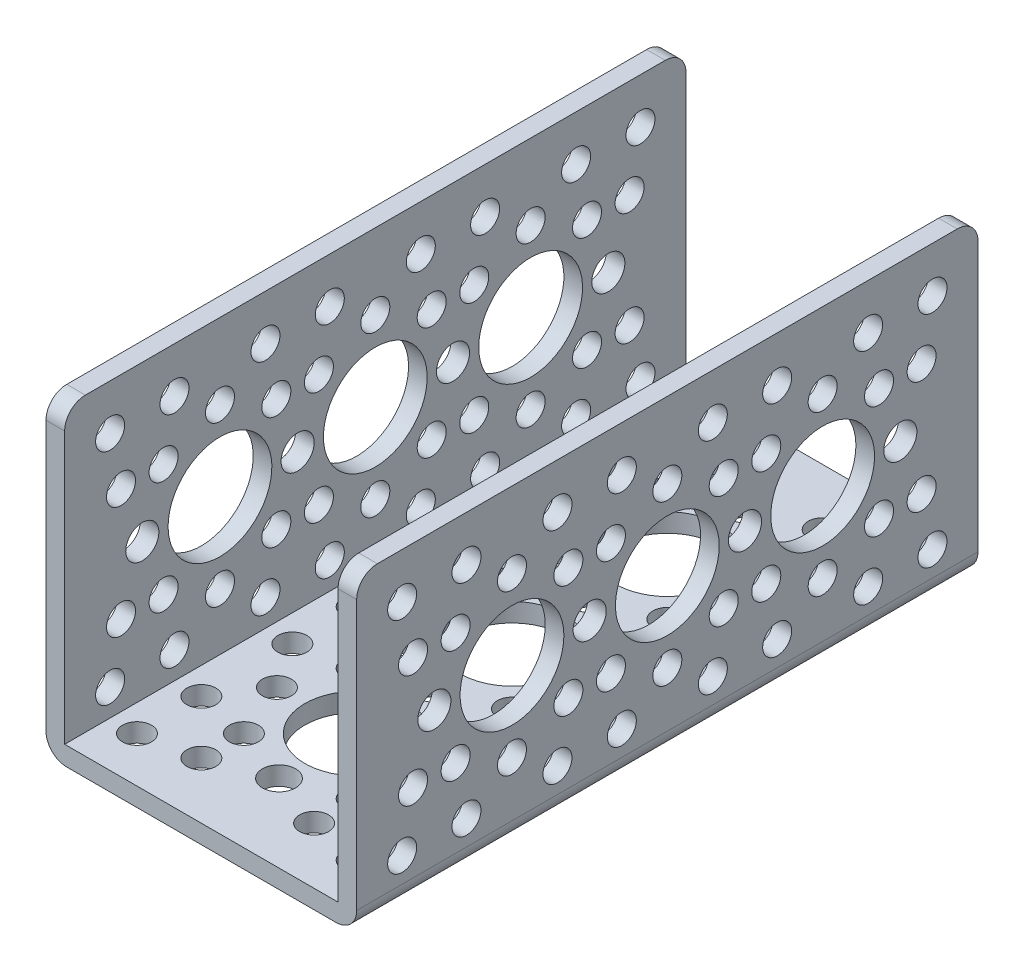
from build123d import *

# Parameters (mm, degrees)
SKETCH1_W                  = 38.1
SKETCH1_H                  = 76.2
BOSS_EXTRUDE1_DEPTH        = 38.1
SKETCH2_W                  = 33.528
SKETCH2_H                  = 35.814
CUT_EXTRUDE1_DEPTH         = 77.2
HOLE1_D                    = 12.7254
HOLE1_DEPTH                = 2.286
M3_CLEARANCE_HOLE1_D       = 3.556
M3_CLEARANCE_HOLE1_DEPTH   = 2.286
M3_5_CLEARANCE_HOLE1_D     = 4.064
M3_5_CLEARANCE_HOLE1_DEPTH = 2.286
HOLE2_D                    = 12.7254
HOLE2_DEPTH                = 38.1
M3_5_CLEARANCE_HOLE2_D     = 4.064
M3_5_CLEARANCE_HOLE2_DEPTH = 38.1
M3_CLEARANCE_HOLE2_D       = 3.556
M3_CLEARANCE_HOLE2_DEPTH   = 38.1
HOLE3_D                    = 12.7254
HOLE3_DEPTH                = 38.1
M3_CLEARANCE_HOLE3_D       = 3.556
M3_CLEARANCE_HOLE3_DEPTH   = 38.1
M3_5_CLEARANCE_HOLE3_D     = 4.064
M3_5_CLEARANCE_HOLE3_DEPTH = 38.1
FILLET1_R                  = 2.54


with BuildPart() as part:
    # Sketch1 → Boss-Extrude1 (new body)
    with BuildSketch(Plane.XZ):
        with Locations((19.05, 38.1)):
            Rectangle(SKETCH1_W, SKETCH1_H)
    extrude(amount=-BOSS_EXTRUDE1_DEPTH)

    # Sketch2 → Cut-Extrude1 (cut, through all)
    with BuildSketch(Plane.XY.offset(76.2)):
        with Locations((19.05, 20.193)):
            Rectangle(SKETCH2_W, SKETCH2_H)
    extrude(amount=-CUT_EXTRUDE1_DEPTH, mode=Mode.SUBTRACT)

    # Hole1
    with Locations(Plane(origin=(38.1, 0, 0), x_dir=(0, 0, -1), z_dir=(1, 0, 0))):
        with Locations((-38.1, 19.05), (-19.05, 19.05), (-57.15, 19.05)):
            Hole(HOLE1_D / 2, depth=HOLE1_DEPTH)

    # M3 Clearance Hole1
    with Locations(Plane(origin=(38.1, 0, 0), x_dir=(0, 0, -1), z_dir=(1, 0, 0))):
        with Locations((-62.729615818, 5.579615818), (-69.285202787, 12.135202787), (-62.729615818, 32.520384182), (-69.285202787, 25.964797213), (-13.470384182, 5.579615818), (-6.914797213, 12.135202787), (-13.470384182, 32.520384182), (-6.914797213, 25.964797213), (-43.679615818, 5.579615818), (-24.629615818, 5.579615818), (-43.679615818, 32.520384182), (-24.629615818, 32.520384182), (-70.620384182, 5.579615818), (-70.620384182, 32.520384182), (-51.570384182, 5.579615818), (-51.570384182, 32.520384182), (-50.235202787, 12.135202787), (-57.15, 9.271), (-64.064797213, 12.135202787), (-64.064797213, 25.964797213), (-57.15, 28.829), (-31.185202787, 12.135202787), (-38.1, 9.271), (-45.014797213, 12.135202787), (-45.014797213, 25.964797213), (-38.1, 28.829), (-50.235202787, 25.964797213), (-31.185202787, 25.964797213), (-32.520384182, 5.579615818), (-32.520384182, 32.520384182), (-5.579615818, 5.579615818), (-5.579615818, 32.520384182), (-12.135202787, 12.135202787), (-19.05, 9.271), (-25.964797213, 12.135202787), (-25.964797213, 25.964797213), (-19.05, 28.829), (-12.135202787, 25.964797213)):
            Hole(M3_CLEARANCE_HOLE1_D / 2, depth=M3_CLEARANCE_HOLE1_DEPTH)

    # M3.5 Clearance Hole1
    with Locations(Plane(origin=(38.1, 0, 0), x_dir=(0, 0, -1), z_dir=(1, 0, 0))):
        with Locations((-66.675, 19.05), (-47.625, 19.05), (-28.575, 19.05), (-9.525, 19.05)):
            Hole(M3_5_CLEARANCE_HOLE1_D / 2, depth=M3_5_CLEARANCE_HOLE1_DEPTH)

    # Hole2
    with Locations(Plane(origin=(0, 0, 0), x_dir=(-1, 0, 0), z_dir=(0, -1, 0))):
        with Locations((-19.05, -57.15), (-19.05, -38.1), (-19.05, -19.05)):
            Hole(HOLE2_D / 2, depth=HOLE2_DEPTH)

    # M3.5 Clearance Hole2
    with Locations(Plane(origin=(0, 0, 0), x_dir=(-1, 0, 0), z_dir=(0, -1, 0))):
        with Locations((-19.05, -66.675), (-19.05, -47.625), (-19.05, -28.575), (-19.05, -9.525)):
            Hole(M3_5_CLEARANCE_HOLE2_D / 2, depth=M3_5_CLEARANCE_HOLE2_DEPTH)

    # M3 Clearance Hole2
    with Locations(Plane(origin=(0, 0, 0), x_dir=(-1, 0, 0), z_dir=(0, -1, 0))):
        with Locations((-5.579615818, -70.620384182), (-5.579615818, -62.729615818), (-12.135202787, -69.285202787), (-32.520384182, -70.620384182), (-32.520384182, -62.729615818), (-25.964797213, -69.285202787), (-5.579615818, -51.570384182), (-5.579615818, -43.679615818), (-32.520384182, -51.570384182), (-32.520384182, -43.679615818), (-12.135202787, -50.235202787), (-9.271, -57.15), (-12.135202787, -64.064797213), (-25.964797213, -64.064797213), (-28.829, -57.15), (-25.964797213, -50.235202787), (-9.271, -38.1), (-12.135202787, -45.014797213), (-25.964797213, -45.014797213), (-28.829, -38.1), (-5.579615818, -32.520384182), (-5.579615818, -24.629615818), (-12.135202787, -31.185202787), (-32.520384182, -32.520384182), (-32.520384182, -24.629615818), (-25.964797213, -31.185202787), (-5.579615818, -5.579615818), (-5.579615818, -13.470384182), (-12.135202787, -6.914797213), (-32.520384182, -5.579615818), (-32.520384182, -13.470384182), (-25.964797213, -6.914797213), (-12.135202787, -12.135202787), (-9.271, -19.05), (-12.135202787, -25.964797213), (-25.964797213, -25.964797213), (-28.829, -19.05), (-25.964797213, -12.135202787)):
            Hole(M3_CLEARANCE_HOLE2_D / 2, depth=M3_CLEARANCE_HOLE2_DEPTH)

    # Hole3
    with Locations(Plane.ZY):
        with Locations((38.1, 19.05), (19.05, 19.05), (57.15, 19.05)):
            Hole(HOLE3_D / 2, depth=HOLE3_DEPTH)

    # M3 Clearance Hole3
    with Locations(Plane.ZY):
        with Locations((62.729615818, 5.579615818), (69.285202787, 12.135202787), (62.729615818, 32.520384182), (69.285202787, 25.964797213), (13.470384182, 5.579615818), (6.914797213, 12.135202787), (13.470384182, 32.520384182), (6.914797213, 25.964797213), (43.679615818, 5.579615818), (24.629615818, 5.579615818), (43.679615818, 32.520384182), (24.629615818, 32.520384182), (70.620384182, 5.579615818), (70.620384182, 32.520384182), (51.570384182, 5.579615818), (51.570384182, 32.520384182), (50.235202787, 12.135202787), (57.15, 9.271), (64.064797213, 12.135202787), (64.064797213, 25.964797213), (57.15, 28.829), (31.185202787, 12.135202787), (38.1, 9.271), (45.014797213, 12.135202787), (45.014797213, 25.964797213), (38.1, 28.829), (50.235202787, 25.964797213), (31.185202787, 25.964797213), (32.520384182, 5.579615818), (32.520384182, 32.520384182), (5.579615818, 5.579615818), (5.579615818, 32.520384182), (12.135202787, 12.135202787), (19.05, 9.271), (25.964797213, 12.135202787), (25.964797213, 25.964797213), (19.05, 28.829), (12.135202787, 25.964797213)):
            Hole(M3_CLEARANCE_HOLE3_D / 2, depth=M3_CLEARANCE_HOLE3_DEPTH)

    # M3.5 Clearance Hole3
    with Locations(Plane.ZY):
        with Locations((66.675, 19.05), (47.625, 19.05), (28.575, 19.05), (9.525, 19.05)):
            Hole(M3_5_CLEARANCE_HOLE3_D / 2, depth=M3_5_CLEARANCE_HOLE3_DEPTH)

    # Fillet1
    fillet1_edges = [part.edges().sort_by_distance(p)[0] for p in [
        (1.143, 38.1, 0),
        (36.957, 38.1, 0),
        (1.143, 38.1, 76.2),
        (0, 0, 38.1),
        (38.1, 0, 38.1),
        (36.957, 38.1, 76.2),
    ]]
    fillet(fillet1_edges, radius=FILLET1_R)


solid = part.part
